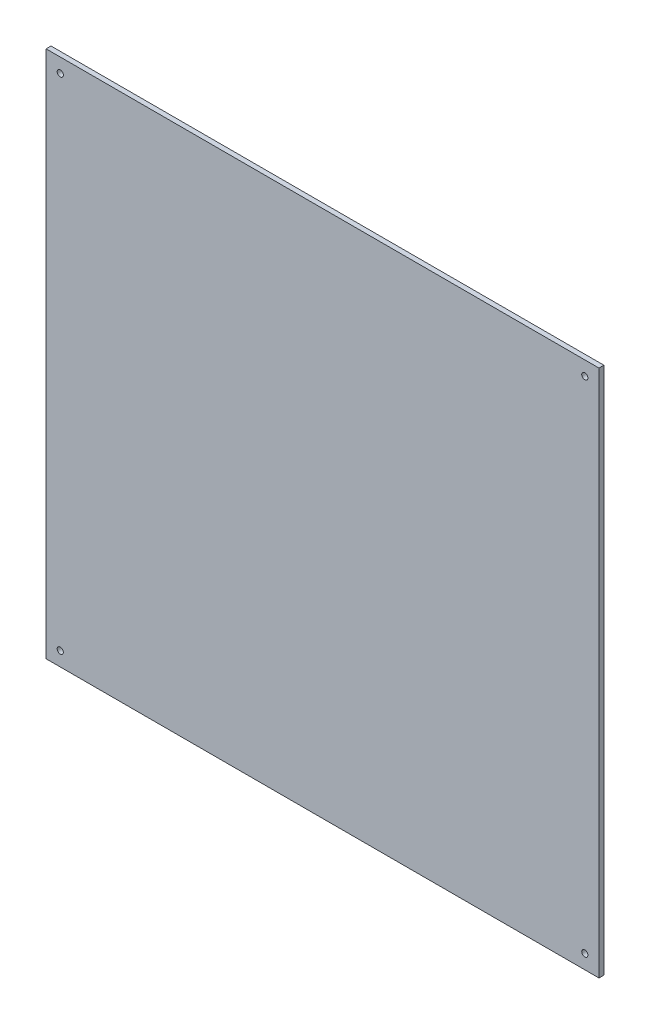
from build123d import *

# Parameters (mm, degrees)
SCHIZZO1_W                   = 449
SCHIZZO1_H                   = 429
SCHIZZO1_R                   = 2.5
ESTRUSIONE_ESTRUSIONE1_DEPTH = 4


with BuildPart() as part:
    # Schizzo1 → Estrusione-Estrusione1 (new body)
    with BuildSketch(Plane.XY):
        with Locations((-224.5, 214.5)):
            Rectangle(SCHIZZO1_W, SCHIZZO1_H)
        with Locations((-437.5, 417.5)):
            Circle(SCHIZZO1_R, mode=Mode.SUBTRACT)
        with Locations((-11.5, 417.5)):
            Circle(SCHIZZO1_R, mode=Mode.SUBTRACT)
        with Locations((-437.5, 11.5)):
            Circle(SCHIZZO1_R, mode=Mode.SUBTRACT)
        with Locations((-11.5, 11.5)):
            Circle(SCHIZZO1_R, mode=Mode.SUBTRACT)
    extrude(amount=ESTRUSIONE_ESTRUSIONE1_DEPTH)


solid = part.part
